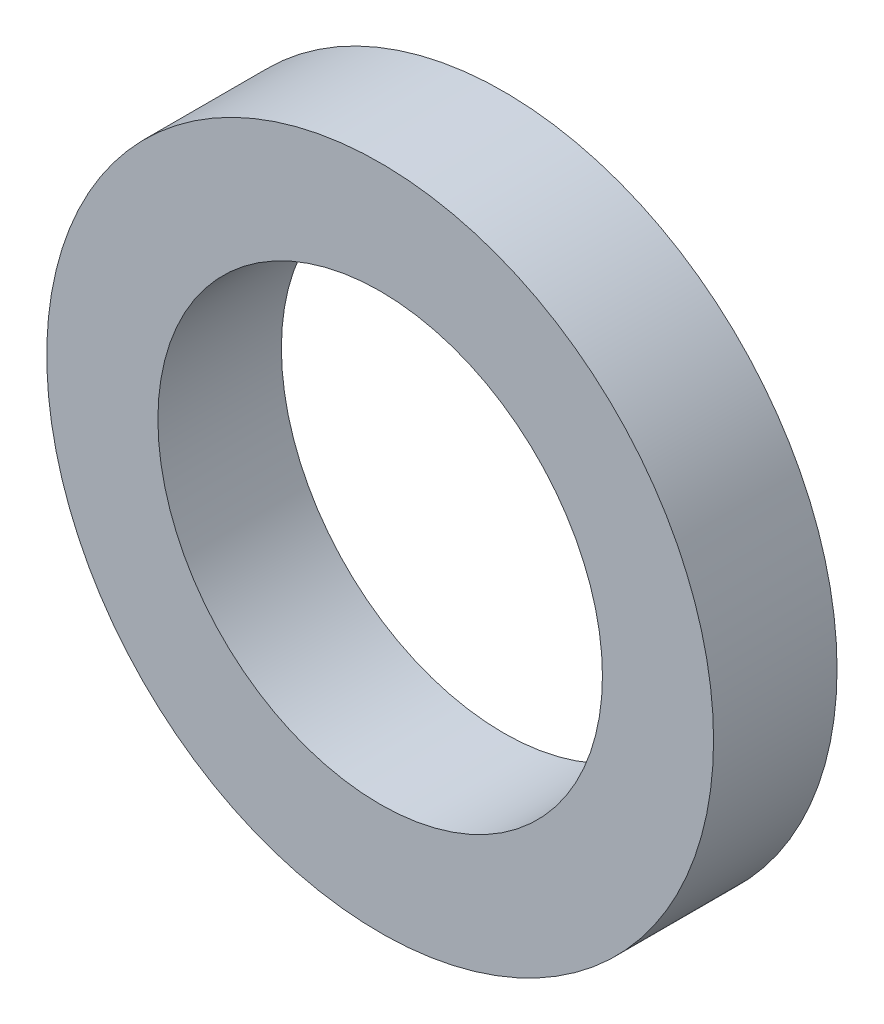
from build123d import *

# Parameters (mm, degrees)
SKETCH_1_R      = 2.7
SKETCH_1_R_2    = 1.8
EXTRUDE_1_DEPTH = 1


with BuildPart() as part:
    # 草图1 → 凸台-拉伸1 (new body)
    with BuildSketch(Plane.XY):
        Circle(SKETCH_1_R)
        Circle(SKETCH_1_R_2, mode=Mode.SUBTRACT)
    extrude(amount=EXTRUDE_1_DEPTH)


solid = part.part
